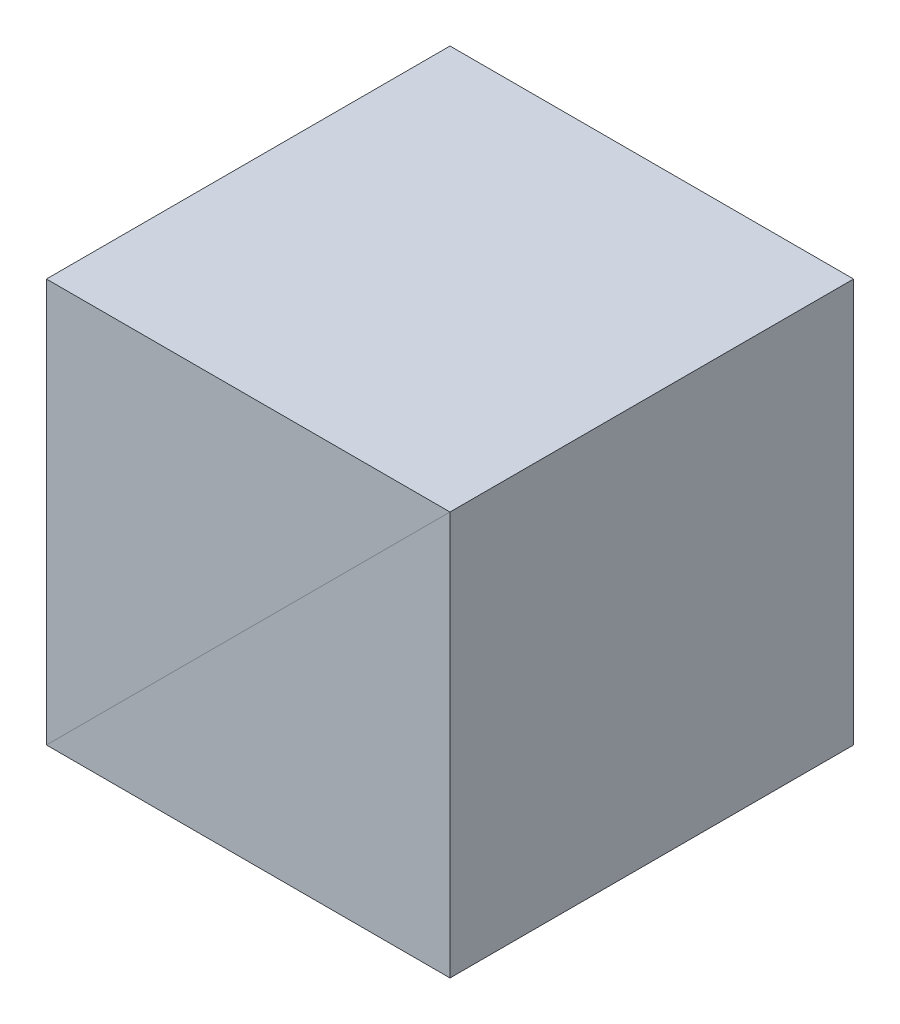
from build123d import *

# Parameters (mm, degrees)
EXTRUDE_1_DEPTH = 5


with BuildPart() as part:
    # 草图1 → 凸台-拉伸1 (new body, symmetric)
    with BuildSketch(Plane.XY):
        Polygon((-5, -5), (5, -5), (5, 5), align=None)
    extrude(amount=EXTRUDE_1_DEPTH, both=True)


with BuildPart() as body_2:
    # 镜向2: mirrored copy
    add(part.part.mirror(Plane(origin=(5, 5, 5), x_dir=(0, 0, 1), z_dir=(0.707106781, -0.707106781, 0))))


solid = Compound([part.part, body_2.part])
